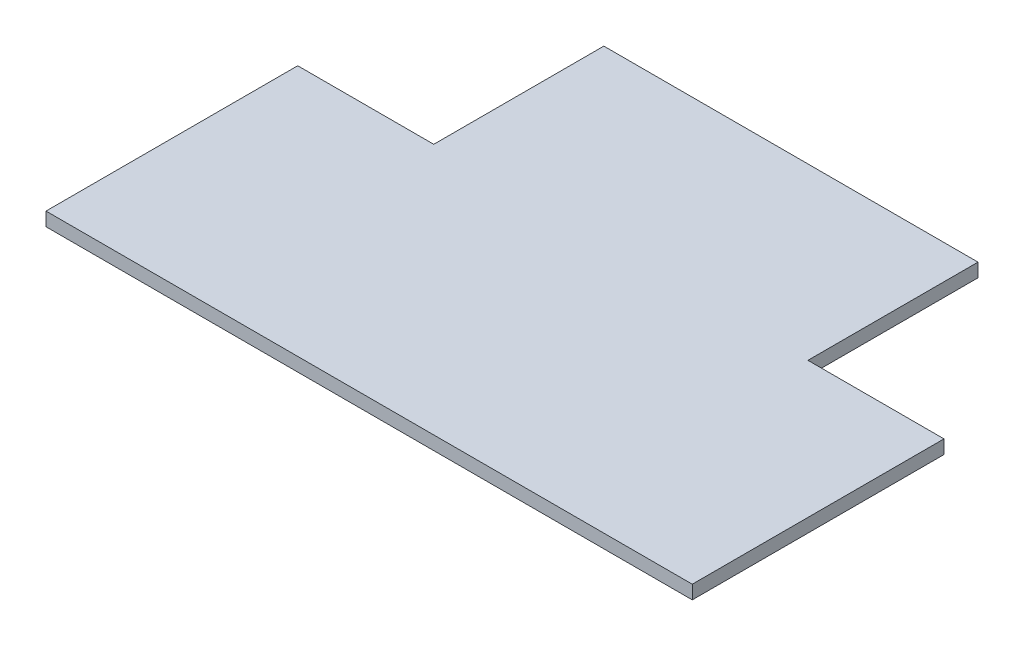
from build123d import *

# Parameters (mm, degrees)
SALIENTE_EXTRUIR1_DEPTH = 2


with BuildPart() as part:
    # Croquis1 → Saliente-Extruir1 (new body)
    with BuildSketch(Plane(origin=(0, 0, 0), x_dir=(1, 0, 0), z_dir=(0, 1, 0))):
        Polygon((-75, -27.399361022), (20, -27.399361022), (20, 9.600638978), (0, 9.600638978), (0, 34.600638978), (-55, 34.600638978), (-55, 9.600638978), (-75, 9.600638978), align=None)
    extrude(amount=SALIENTE_EXTRUIR1_DEPTH)


solid = part.part
